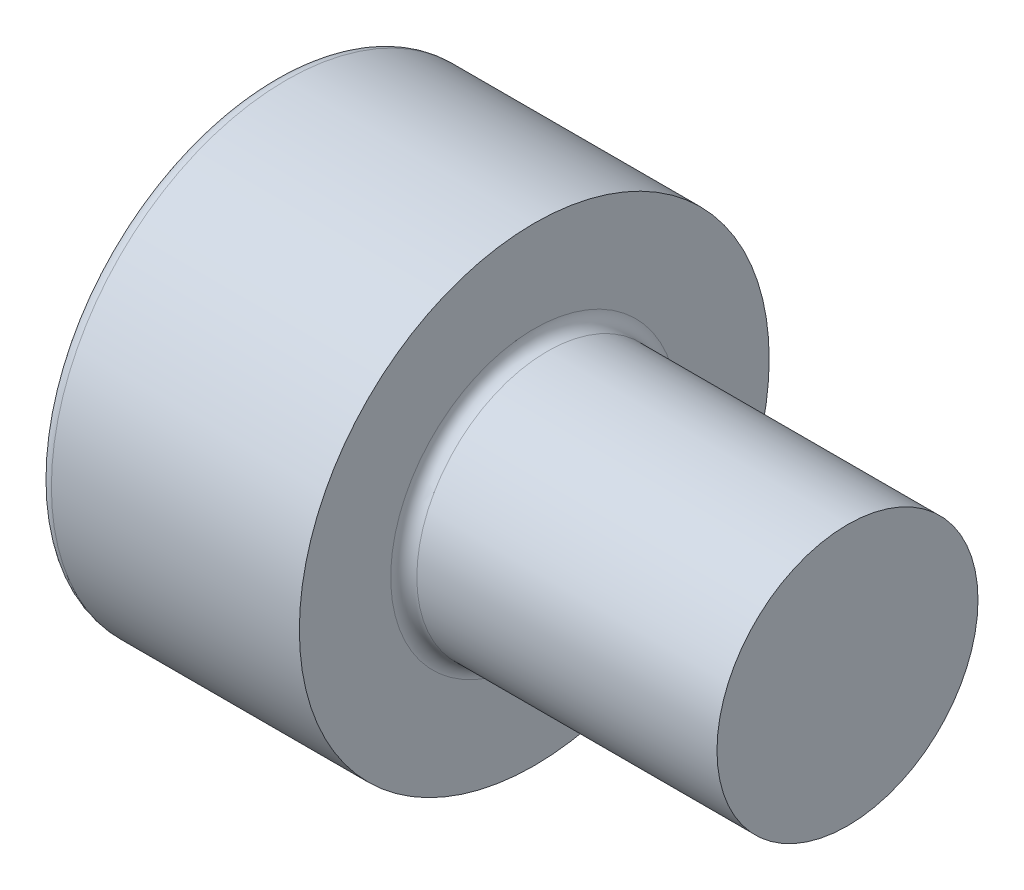
from build123d import *

# Parameters (mm, degrees)
SKETCH1_W               = 2.5
SKETCH1_H               = 2.25
SKETCH2_R               = 1.25
BOSS_EXTRUDE1_DEPTH     = 8
CUT_EXTRUDE1_DEPTH      = 1.1
CHAMFER1_SIZE           = 0.2535
FILLET1_R               = 0.125
SKETCH5_W               = 5
SKETCH5_H               = 4.609791228
CUT_EXTRUDE2_DEPTH      = 10
CUT_EXTRUDE2_DEPTH_BACK = 10


with BuildPart() as part:
    # Sketch1 → Revolve1 (revolve)
    with BuildSketch(Plane(origin=(0, 0, 0), x_dir=(-1, 0, 0), z_dir=(0, 0, -1))):
        with Locations((-1.25, 1.125)):
            Rectangle(SKETCH1_W, SKETCH1_H)
    revolve(axis=Axis((2.5, 0, 0), (-1, 0, 0)))

    # Sketch2 → Boss-Extrude1 (add)
    with BuildSketch(Plane(origin=(2.5, 0, 0), x_dir=(0, 0, -1), z_dir=(1, 0, 0))):
        Circle(SKETCH2_R)
    extrude(amount=BOSS_EXTRUDE1_DEPTH)

    # Sketch3 → Cut-Extrude1 (cut)
    with BuildSketch(Plane.ZY):
        Polygon((-1.0225, -0.59034065), (0, -1.1806813), (1.0225, -0.59034065), (1.0225, 0.59034065), (0, 1.1806813), (-1.0225, 0.59034065), align=None)
    extrude(amount=-CUT_EXTRUDE1_DEPTH, mode=Mode.SUBTRACT)

    # Sketch4 → Cut-Revolve1 (revolve, cut)
    with BuildSketch(Plane.XY):
        Polygon((1.1, 1.0225), (1.1, 0), (1.69034065, 0), align=None)
    revolve(axis=Axis((1.099975, 0, 0), (1, 0, 0)), mode=Mode.SUBTRACT)

    # Chamfer1
    chamfer1_edges = [part.edges().sort_by_distance(p)[0] for p in [
        (10.5, 0, 1.25),
    ]]
    chamfer(chamfer1_edges, length=CHAMFER1_SIZE)

    # Fillet1
    fillet1_edges = [part.edges().sort_by_distance(p)[0] for p in [
        (0, -2.25, 0),
        (2.5, 0, 1.25),
    ]]
    fillet(fillet1_edges, radius=FILLET1_R)

    # Sketch5 → Cut-Extrude2 (cut, two sides)
    with BuildSketch(Plane.XY) as cut_extrude2_sk:
        with Locations((8, -0.404062901)):
            Rectangle(SKETCH5_W, SKETCH5_H)
    extrude(amount=CUT_EXTRUDE2_DEPTH, mode=Mode.SUBTRACT)
    extrude(cut_extrude2_sk.sketch, amount=-CUT_EXTRUDE2_DEPTH_BACK, mode=Mode.SUBTRACT)


solid = part.part
